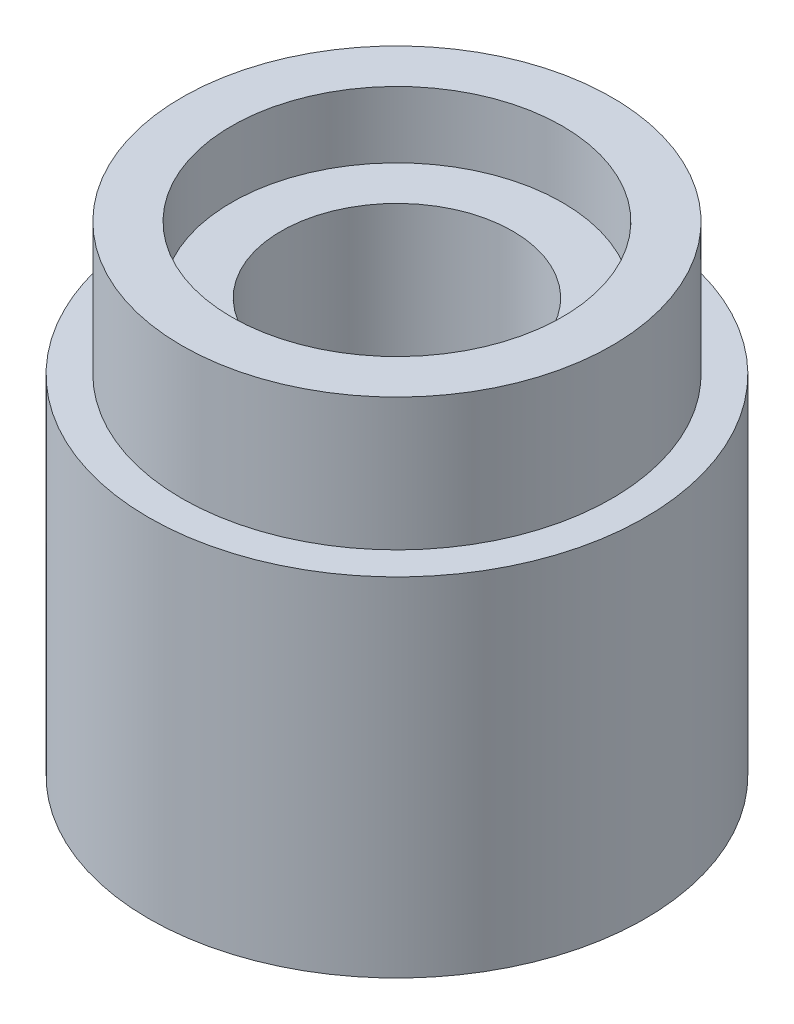
from build123d import *

# Parameters (mm, degrees)
SKETCH1_R           = 3.75
BOSS_EXTRUDE1_DEPTH = 7.25
SKETCH3_R           = 3.75
SKETCH3_R_2         = 3.25
CUT_EXTRUDE1_DEPTH  = 2
SKETCH4_R           = 1.75
CUT_EXTRUDE2_DEPTH  = 6.75
SKETCH5_R           = 2.5
CUT_EXTRUDE3_DEPTH  = 1


with BuildPart() as part:
    # Sketch1 → Boss-Extrude1 (new body)
    with BuildSketch(Plane(origin=(0, 0, 0), x_dir=(1, 0, 0), z_dir=(0, 1, 0))):
        Circle(SKETCH1_R)
    extrude(amount=BOSS_EXTRUDE1_DEPTH)

    # Sketch3 → Cut-Extrude1 (cut)
    with BuildSketch(Plane(origin=(0, 7.25, 0), x_dir=(1, 0, 0), z_dir=(0, 1, 0))):
        Circle(SKETCH3_R)
        Circle(SKETCH3_R_2, mode=Mode.SUBTRACT)
    extrude(amount=-CUT_EXTRUDE1_DEPTH, mode=Mode.SUBTRACT)

    # Sketch4 → Cut-Extrude2 (cut)
    with BuildSketch(Plane(origin=(0, 7.25, 0), x_dir=(1, 0, 0), z_dir=(0, 1, 0))):
        Circle(SKETCH4_R)
    extrude(amount=-CUT_EXTRUDE2_DEPTH, mode=Mode.SUBTRACT)

    # Sketch5 → Cut-Extrude3 (cut)
    with BuildSketch(Plane(origin=(0, 7.25, 0), x_dir=(1, 0, 0), z_dir=(0, 1, 0))):
        Circle(SKETCH5_R)
    extrude(amount=-CUT_EXTRUDE3_DEPTH, mode=Mode.SUBTRACT)


solid = part.part
